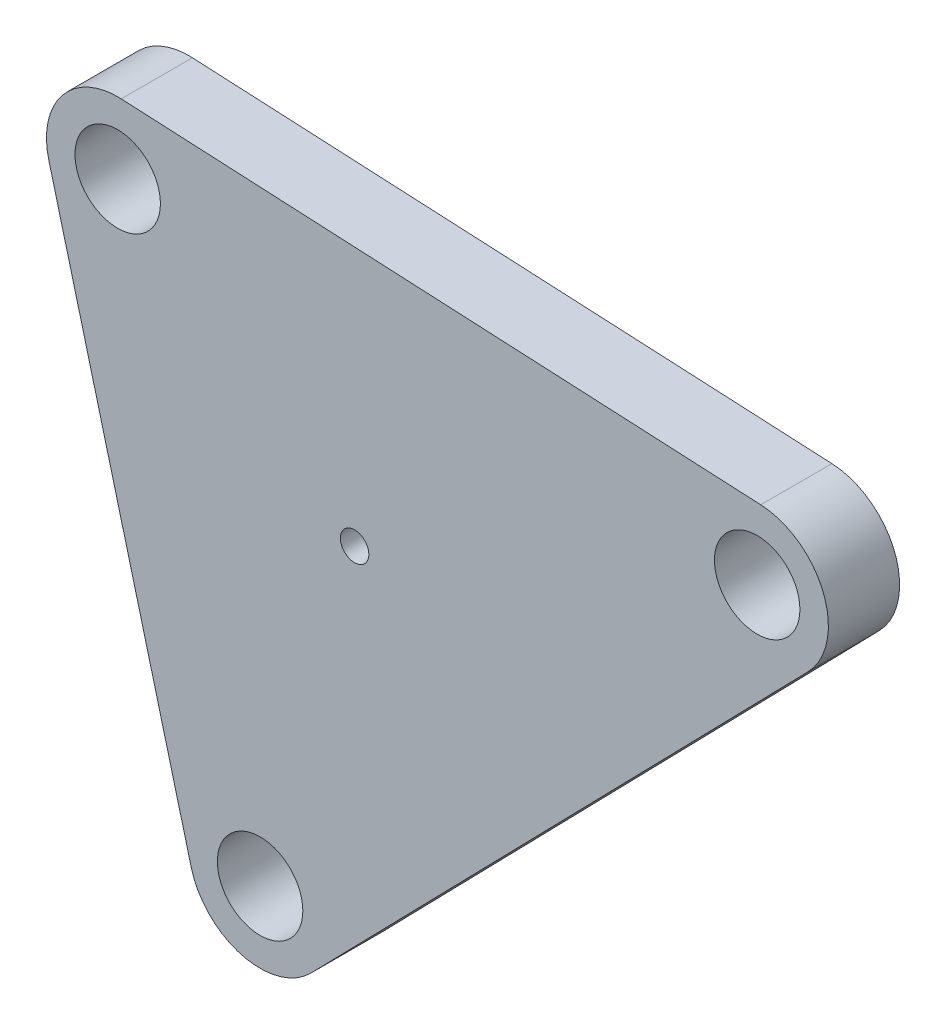
from build123d import *

# Parameters (mm, degrees)
ESQUISSE1_R      = 3
ESQUISSE1_R_2    = 1
EXTRUSION1_DEPTH = 5


with BuildPart() as part:
    # Esquisse1 → Extrusion1 (new body)
    with BuildSketch(Plane.XY):
        with BuildLine():
            Line((52.730599116, -2.952254244), (7.830086245, -0.723670796))
            ThreePointArc((7.830086245, -0.723670796), (3.699182558, -2.567602385), (2.746849637, -6.989989861))
            Line((2.746849637, -6.989989861), (12.746849637, -44.989989861))
            ThreePointArc((12.746849637, -44.989989861), (16.307085805, -48.552192625), (21.161053557, -47.209223095))
            Line((21.161053557, -47.209223095), (56.061566429, -11.437806542))
            ThreePointArc((56.061566429, -11.437806542), (57.136985769, -6.119100628), (52.730599116, -2.952254244))
        make_face()
        with Locations((7.582222324, -5.717523364)):
            Circle(ESQUISSE1_R, mode=Mode.SUBTRACT)
        with Locations((52.482735195, -7.946106812)):
            Circle(ESQUISSE1_R, mode=Mode.SUBTRACT)
        with Locations((17.582222324, -43.717523364)):
            Circle(ESQUISSE1_R, mode=Mode.SUBTRACT)
        with Locations((24.216673772, -19.733908354)):
            Circle(ESQUISSE1_R_2, mode=Mode.SUBTRACT)
    extrude(amount=EXTRUSION1_DEPTH)


solid = part.part
